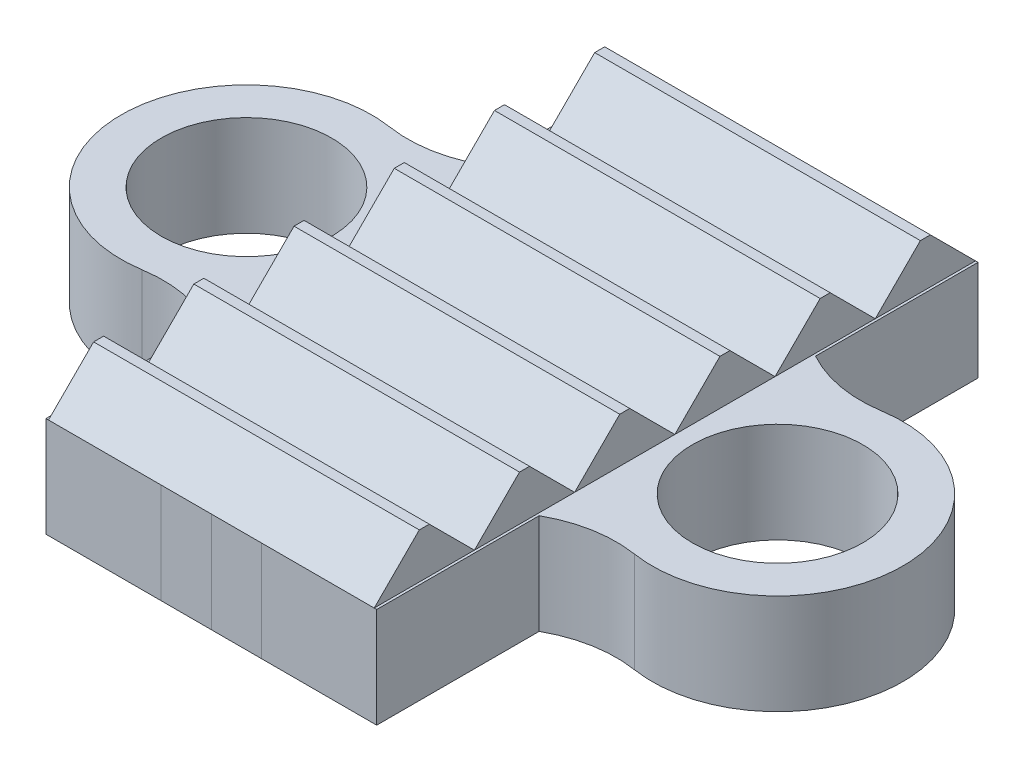
from build123d import *

# Parameters (mm, degrees)
CROQUIS1_R              = 1.7
SALIENTE_EXTRUIR1_DEPTH = 2
SALIENTE_EXTRUIR2_DEPTH = 6.5
MATRIZL1_COUNT          = 6
MATRIZL1_PITCH          = 2
SKETCH1_W               = 2
SKETCH1_H               = 2
CUT_EXTRUDE1_DEPTH      = 0.1
SKETCH1_3_W             = 1
SKETCH1_3_H             = 2
BOSS_EXTRUDE1_DEPTH     = 0.1
SKETCH1_4_W             = 1
SKETCH1_4_H             = 2
BOSS_EXTRUDE2_DEPTH     = 0.1


with BuildPart() as part:
    # Croquis1 → Saliente-Extruir1 (new body)
    with BuildSketch(Plane(origin=(0, 0, 0), x_dir=(1, 0, 0), z_dir=(0, 1, 0))):
        with BuildLine():
            Line((3.3, 6), (-3.3, 6))
            Line((-3.3, 6), (-3.3, 2.758060528))
            ThreePointArc((-3.3, 2.758060528), (-4.081204524, 2.478243977), (-4.910964812, 2.469544821))
            ThreePointArc((-4.910964812, 2.469544821), (-7.8, 0), (-4.910964812, -2.469544821))
            ThreePointArc((-4.910964812, -2.469544821), (-4.081204524, -2.478243977), (-3.3, -2.758060528))
            Line((-3.3, -2.758060528), (-3.3, -6))
            Line((-3.3, -6), (3.3, -6))
            Line((3.3, -6), (3.3, -2.758060528))
            ThreePointArc((3.3, -2.758060528), (4.081204524, -2.478243977), (4.910964812, -2.469544821))
            ThreePointArc((4.910964812, -2.469544821), (7.8, 0), (4.910964812, 2.469544821))
            ThreePointArc((4.910964812, 2.469544821), (4.081204524, 2.478243977), (3.3, 2.758060528))
            Line((3.3, 2.758060528), (3.3, 6))
        make_face()
        with Locations((5.3, 0)):
            Circle(CROQUIS1_R, mode=Mode.SUBTRACT)
        with Locations((-5.3, 0)):
            Circle(CROQUIS1_R, mode=Mode.SUBTRACT)
    extrude(amount=SALIENTE_EXTRUIR1_DEPTH)

    # Croquis4 → Saliente-Extruir2 (add)
    with BuildSketch(Plane(origin=(3.25, 0, 0), x_dir=(0, 0, -1), z_dir=(1, 0, 0))):
        Polygon((-6, 2), (-4, 2), (-4.9, 2.9), (-5.1, 2.9), align=None)
    saliente_extruir2 = extrude(amount=-SALIENTE_EXTRUIR2_DEPTH)

    # MatrizL1: Saliente-Extruir2 ×6
    with Locations(*[(0, 0, -i * MATRIZL1_PITCH) for i in range(1, MATRIZL1_COUNT)]):
        add(saliente_extruir2)

    # Sketch1 → Cut-Extrude1 (cut)
    with BuildSketch(Plane.XY.offset(6)):
        with Locations((0, 1)):
            Rectangle(SKETCH1_W, SKETCH1_H)
    extrude(amount=-CUT_EXTRUDE1_DEPTH, mode=Mode.SUBTRACT)


with BuildPart() as body_2:
    # Sketch1_3 → Boss-Extrude1 (new body)
    with BuildSketch(Plane.XY.offset(6)):
        with Locations((0.5, 1)):
            Rectangle(SKETCH1_3_W, SKETCH1_3_H)
    extrude(amount=-BOSS_EXTRUDE1_DEPTH)


with BuildPart() as body_3:
    # Sketch1_4 → Boss-Extrude2 (new body)
    with BuildSketch(Plane.XY.offset(6)):
        with Locations((-0.5, 1)):
            Rectangle(SKETCH1_4_W, SKETCH1_4_H)
    extrude(amount=-BOSS_EXTRUDE2_DEPTH)


solid = Compound([part.part, body_2.part, body_3.part])
